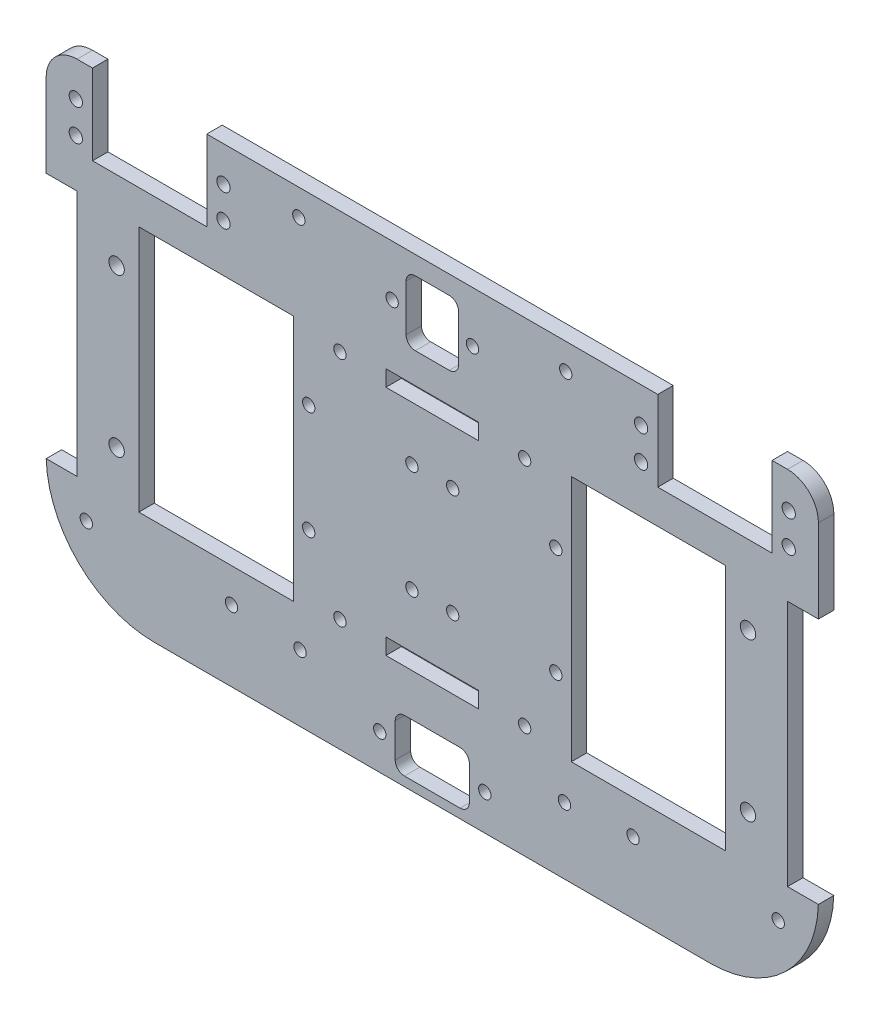
from build123d import *

# Parameters (mm, degrees)
BOSS_EXTRUDE1_DEPTH = 5
SKETCH2_R           = 2
SKETCH2_W           = 10
SKETCH2_H           = 80
SKETCH2_W_2         = 50
SKETCH2_H_2         = 80.000000001
CUT_EXTRUDE1_DEPTH  = 10
SKETCH4_W           = 30
SKETCH4_H           = 5.2
CUT_EXTRUDE3_DEPTH  = 10
SKETCH6_R           = 2.5
CUT_EXTRUDE5_DEPTH  = 10
SKETCH7_R           = 2
CUT_EXTRUDE6_DEPTH  = 10
CUT_EXTRUDE7_DEPTH  = 70
SKETCH10_R          = 2
CUT_EXTRUDE8_DEPTH  = 5
SKETCH11_R          = 2
CUT_EXTRUDE9_DEPTH  = 10
SKETCH16_W          = 37
SKETCH16_H          = 26
CUT_EXTRUDE10_DEPTH = 10
SKETCH17_R          = 2.15
CUT_EXTRUDE11_DEPTH = 10
SKETCH18_R          = 2
CUT_EXTRUDE12_DEPTH = 10
SKETCH24_R          = 2
CUT_EXTRUDE17_DEPTH = 5
SKETCH26_R          = 2
CUT_EXTRUDE18_DEPTH = 10


with BuildPart() as part:
    # Sketch1 → Boss-Extrude1 (new body)
    with BuildSketch(Plane.XY):
        with BuildLine():
            Line((-115, 77), (115, 77))
            ThreePointArc((115, 77), (122.071067812, 74.071067812), (125, 67))
            Line((125, 67), (125, -39))
            ThreePointArc((125, -39), (114.748737342, -63.748737342), (90, -74))
            Line((90, -74), (-90, -74))
            ThreePointArc((-90, -74), (-114.748737342, -63.748737342), (-125, -39))
            Line((-125, -39), (-125, 67))
            ThreePointArc((-125, 67), (-122.071067812, 74.071067812), (-115, 77))
        make_face()
    extrude(amount=BOSS_EXTRUDE1_DEPTH)

    # Sketch2 → Cut-Extrude1 (cut)
    with BuildSketch(Plane(origin=(0, 0, 0), x_dir=(-1, 0, 0), z_dir=(0, 0, -1))):
        with Locations((-6.6, -17.5)):
            Circle(SKETCH2_R)
        with Locations((-6.6, 17.5)):
            Circle(SKETCH2_R)
        with Locations((-40, -17.5)):
            Circle(SKETCH2_R)
        with Locations((-40, 17.5)):
            Circle(SKETCH2_R)
        with Locations((6.6, 17.5)):
            Circle(SKETCH2_R)
        with Locations((6.6, -17.5)):
            Circle(SKETCH2_R)
        with Locations((40, -17.5)):
            Circle(SKETCH2_R)
        with Locations((40, 17.5)):
            Circle(SKETCH2_R)
        with Locations((-120, 0)):
            Rectangle(SKETCH2_W, SKETCH2_H)
        with Locations((-70, -1e-09)):
            Rectangle(SKETCH2_W_2, SKETCH2_H_2)
        with Locations((120, 0)):
            Rectangle(SKETCH2_W, SKETCH2_H)
        with Locations((70, -1e-09)):
            Rectangle(SKETCH2_W_2, SKETCH2_H_2)
    extrude(amount=-CUT_EXTRUDE1_DEPTH, mode=Mode.SUBTRACT)

    # Sketch4 → Cut-Extrude3 (cut)
    with BuildSketch(Plane(origin=(0, 0, 0), x_dir=(-1, 0, 0), z_dir=(0, 0, -1))):
        with Locations((0, -37.6)):
            Rectangle(SKETCH4_W, SKETCH4_H)
        with Locations((0, 37.6)):
            Rectangle(SKETCH4_W, SKETCH4_H)
    extrude(amount=-CUT_EXTRUDE3_DEPTH, mode=Mode.SUBTRACT)

    # Sketch6 → Cut-Extrude5 (cut)
    with BuildSketch(Plane(origin=(0, 0, 0), x_dir=(-1, 0, 0), z_dir=(0, 0, -1))):
        with Locations((-102.2, -25.5)):
            Circle(SKETCH6_R)
        with Locations((-102.2, 25.5)):
            Circle(SKETCH6_R)
        with Locations((102.2, -25.5)):
            Circle(SKETCH6_R)
        with Locations((102.2, 25.5)):
            Circle(SKETCH6_R)
    extrude(amount=-CUT_EXTRUDE5_DEPTH, mode=Mode.SUBTRACT)

    # Sketch7 → Cut-Extrude6 (cut)
    with BuildSketch(Plane(origin=(0, 0, 0), x_dir=(-1, 0, 0), z_dir=(0, 0, -1))):
        with Locations((29.9, 37.5)):
            Circle(SKETCH7_R)
        with Locations((-29.9, -37.5)):
            Circle(SKETCH7_R)
        with Locations((-29.9, 37.5)):
            Circle(SKETCH7_R)
        with Locations((29.9, -37.5)):
            Circle(SKETCH7_R)
    extrude(amount=-CUT_EXTRUDE6_DEPTH, mode=Mode.SUBTRACT)

    # Sketch8 → Cut-Extrude7 (cut)
    with BuildSketch(Plane(origin=(0, 0, 0), x_dir=(-1, 0, 0), z_dir=(0, 0, -1))):
        with BuildLine():
            Line((5.5, 71), (-5.5, 71))
            ThreePointArc((-5.5, 71), (-7.621320344, 70.121320344), (-8.5, 68))
            Line((-8.5, 68), (-8.5, 53))
            ThreePointArc((-8.5, 53), (-7.621320344, 50.878679656), (-5.5, 50))
            Line((-5.5, 50), (5.5, 50))
            ThreePointArc((5.5, 50), (7.621320344, 50.878679656), (8.5, 53))
            Line((8.5, 53), (8.5, 68))
            ThreePointArc((8.5, 68), (7.621320344, 70.121320344), (5.5, 71))
        make_face()
    extrude(amount=-CUT_EXTRUDE7_DEPTH, mode=Mode.SUBTRACT)

    # Sketch10 → Cut-Extrude8 (cut)
    with BuildSketch(Plane(origin=(0, 0, 0), x_dir=(-1, 0, 0), z_dir=(0, 0, -1))):
        with Locations((13, 60.5)):
            Circle(SKETCH10_R)
        with Locations((-13, 60.5)):
            Circle(SKETCH10_R)
    extrude(amount=-CUT_EXTRUDE8_DEPTH, mode=Mode.SUBTRACT)

    # Sketch11 → Cut-Extrude9 (cut)
    with BuildSketch(Plane(origin=(0, 0, 0), x_dir=(-1, 0, 0), z_dir=(0, 0, -1))):
        with Locations((-17, -62.5)):
            Circle(SKETCH11_R)
        with Locations((17, -62.5)):
            Circle(SKETCH11_R)
        with BuildLine():
            Line((-9, -54), (9, -54))
            ThreePointArc((9, -54), (11.121320344, -54.878679656), (12, -57))
            Line((12, -57), (12, -68))
            ThreePointArc((12, -68), (11.121320344, -70.121320344), (9, -71))
            Line((9, -71), (-9, -71))
            ThreePointArc((-9, -71), (-11.121320344, -70.121320344), (-12, -68))
            Line((-12, -68), (-12, -57))
            ThreePointArc((-12, -57), (-11.121320344, -54.878679656), (-9, -54))
        make_face()
    extrude(amount=-CUT_EXTRUDE9_DEPTH, mode=Mode.SUBTRACT)

    # Sketch16 → Cut-Extrude10 (cut)
    with BuildSketch(Plane(origin=(0, 0, 0), x_dir=(-1, 0, 0), z_dir=(0, 0, -1))):
        with Locations((-91.5, 64)):
            Rectangle(SKETCH16_W, SKETCH16_H)
        with Locations((91.5, 64)):
            Rectangle(SKETCH16_W, SKETCH16_H)
    extrude(amount=-CUT_EXTRUDE10_DEPTH, mode=Mode.SUBTRACT)

    # Sketch17 → Cut-Extrude11 (cut)
    with BuildSketch(Plane(origin=(0, 0, 0), x_dir=(-1, 0, 0), z_dir=(0, 0, -1))):
        with Locations((67.6, 65.6)):
            Circle(SKETCH17_R)
        with Locations((67.6, 55.4)):
            Circle(SKETCH17_R)
        with Locations((115.4, 55.4)):
            Circle(SKETCH17_R)
        with Locations((115.4, 65.6)):
            Circle(SKETCH17_R)
        with Locations((-115.4, 65.6)):
            Circle(SKETCH17_R)
        with Locations((-115.4, 55.4)):
            Circle(SKETCH17_R)
        with Locations((-67.6, 55.4)):
            Circle(SKETCH17_R)
        with Locations((-67.6, 65.6)):
            Circle(SKETCH17_R)
    extrude(amount=-CUT_EXTRUDE11_DEPTH, mode=Mode.SUBTRACT)

    # Sketch18 → Cut-Extrude12 (cut)
    with BuildSketch(Plane(origin=(0, 0, 0), x_dir=(-1, 0, 0), z_dir=(0, 0, -1))):
        with Locations((-43.2, 68.5)):
            Circle(SKETCH18_R)
        with Locations((43.2, 68.5)):
            Circle(SKETCH18_R)
    extrude(amount=-CUT_EXTRUDE12_DEPTH, mode=Mode.SUBTRACT)

    # Sketch24 → Cut-Extrude17 (cut)
    with BuildSketch(Plane(origin=(0, 0, 0), x_dir=(-1, 0, 0), z_dir=(0, 0, -1))):
        with Locations((-42.8, -52.5)):
            Circle(SKETCH24_R)
        with Locations((42.8, -52.5)):
            Circle(SKETCH24_R)
    extrude(amount=-CUT_EXTRUDE17_DEPTH, mode=Mode.SUBTRACT)

    # Sketch26 → Cut-Extrude18 (cut)
    with BuildSketch(Plane(origin=(0, 0, 0), x_dir=(-1, 0, 0), z_dir=(0, 0, -1))):
        with Locations((-112, -51)):
            Circle(SKETCH26_R)
        with Locations((-65, -51)):
            Circle(SKETCH26_R)
        with Locations((65, -51)):
            Circle(SKETCH26_R)
        with Locations((112, -51)):
            Circle(SKETCH26_R)
    extrude(amount=-CUT_EXTRUDE18_DEPTH, mode=Mode.SUBTRACT)


solid = part.part
